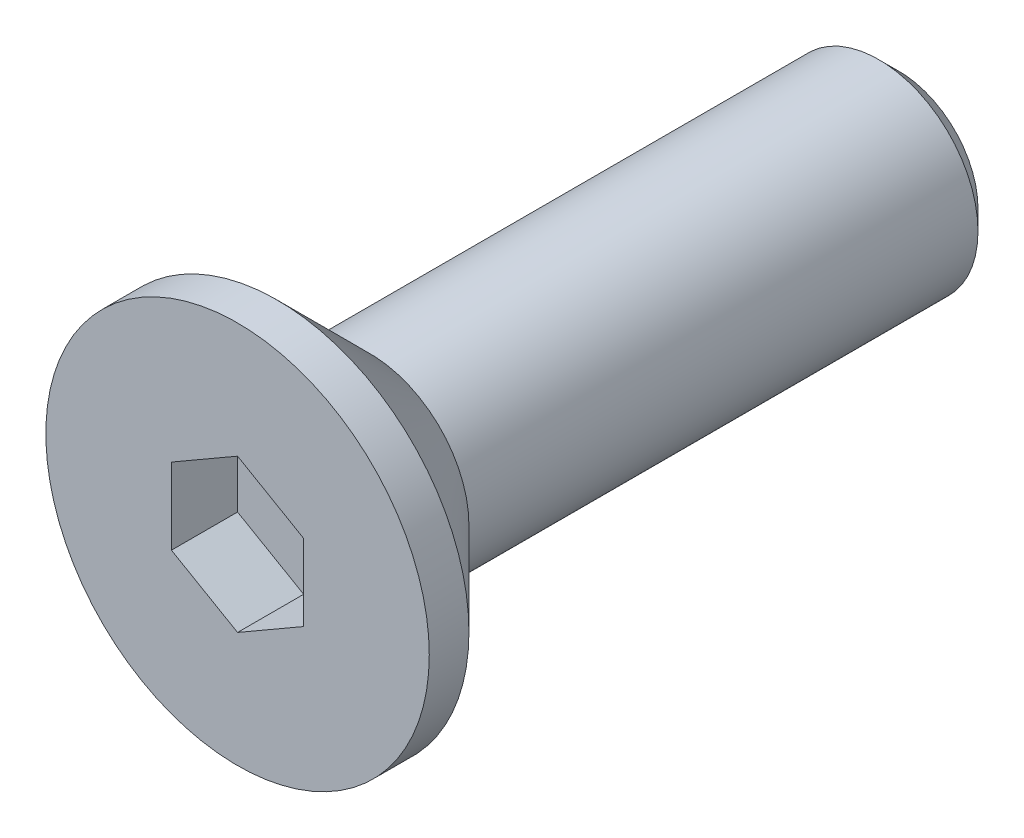
from build123d import *

# Parameters (mm, degrees)
SCHNITT_LINEAR_AUSTRAGEN1_DEPTH = 1
FASE1_SIZE                      = 0.3


with BuildPart() as part:
    # Skizze1 → Rotation1 (revolve)
    with BuildSketch(Plane(origin=(0, 0, 0), x_dir=(0, 0, -1), z_dir=(1, 0, 0))):
        Polygon((0, 0), (0, 2.9), (0.6, 2.9), (2, 1.5), (10, 1.5), (10, 0), align=None)
    revolve(axis=Axis((0, 0, 31.763581507), (0, 0, -1)))

    # Skizze3 → Schnitt-Linear austragen1 (cut)
    with BuildSketch(Plane.XY):
        Polygon((1, -0.577350269), (1, 0.577350269), (0, 1.154700538), (-1, 0.577350269), (-1, -0.577350269), (0, -1.154700538), align=None)
    extrude(amount=-SCHNITT_LINEAR_AUSTRAGEN1_DEPTH, mode=Mode.SUBTRACT)

    # Fase1
    fase1_edges = [part.edges().sort_by_distance(p)[0] for p in [
        (0, -1.5, -10),
    ]]
    chamfer(fase1_edges, length=FASE1_SIZE)


solid = part.part
